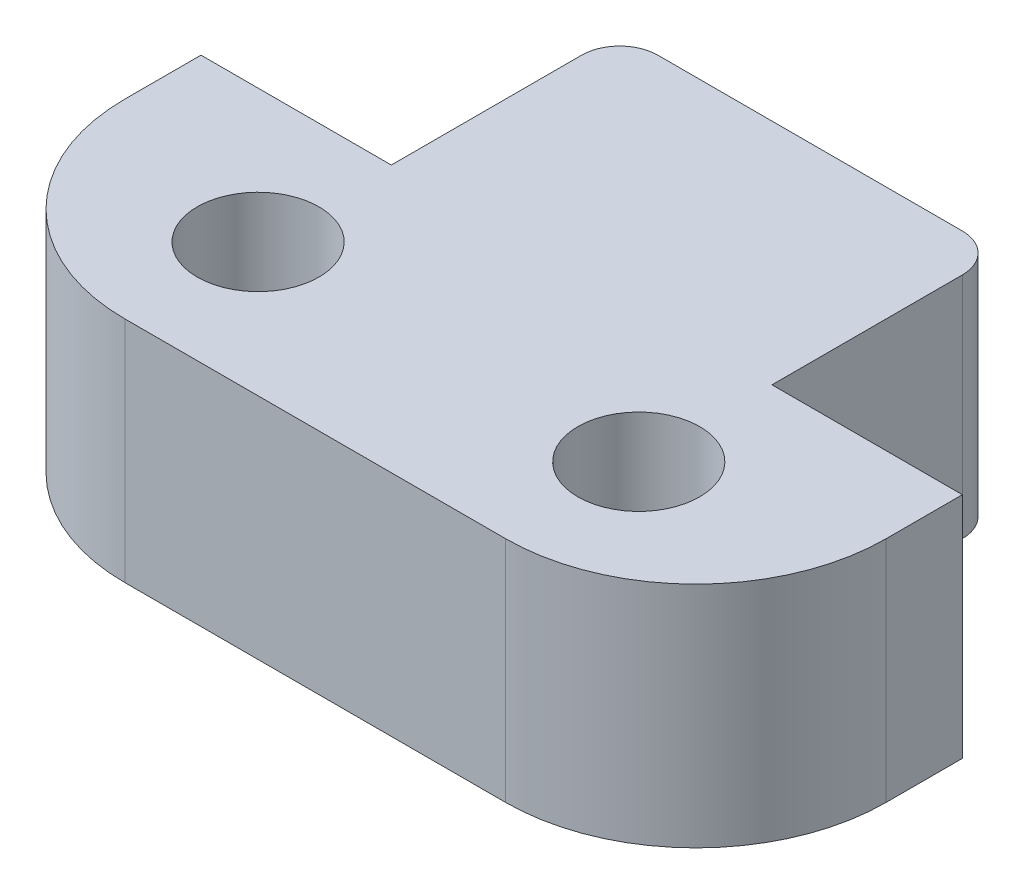
from build123d import *

# Parameters (mm, degrees)
SKETCH1_W             = 20
SKETCH1_H             = 7
BOSS_EXTRUDE1_DEPTH   = 6
SKETCH234_W           = 10
SKETCH234_H           = 6
BOSS_EXTRUDE234_DEPTH = 6
FILLET134_R           = 1
M3_CLEARANCE_HOLE1_D  = 3.2
FILLET135_R           = 5


with BuildPart() as part:
    # Sketch1 → Boss-Extrude1 (new body)
    with BuildSketch(Plane(origin=(0, 0, 0), x_dir=(1, 0, 0), z_dir=(0, 1, 0))):
        Rectangle(SKETCH1_W, SKETCH1_H)
    extrude(amount=BOSS_EXTRUDE1_DEPTH)

    # Sketch234 → Boss-Extrude234 (add)
    with BuildSketch(Plane(origin=(0.767778608, 0, -3.5), x_dir=(-1, 0, 0), z_dir=(0, 0, -1))):
        with Locations((0.767778608, 3)):
            Rectangle(SKETCH234_W, SKETCH234_H)
    extrude(amount=BOSS_EXTRUDE234_DEPTH)

    # Fillet134
    fillet134_edges = [part.edges().sort_by_distance(p)[0] for p in [
        (5, 3, -9.5),
        (-5, 3, -9.5),
    ]]
    fillet(fillet134_edges, radius=FILLET134_R)

    # M3 Clearance Hole1 (through all)
    with Locations(Plane(origin=(0, 6, 0), x_dir=(1, 0, 0), z_dir=(0, 1, 0))):
        with Locations((-5, 0), (5, 0)):
            Hole(M3_CLEARANCE_HOLE1_D / 2)

    # Fillet135
    fillet135_edges = [part.edges().sort_by_distance(p)[0] for p in [
        (10, 3, 3.5),
        (-10, 3, 3.5),
    ]]
    fillet(fillet135_edges, radius=FILLET135_R)


solid = part.part
